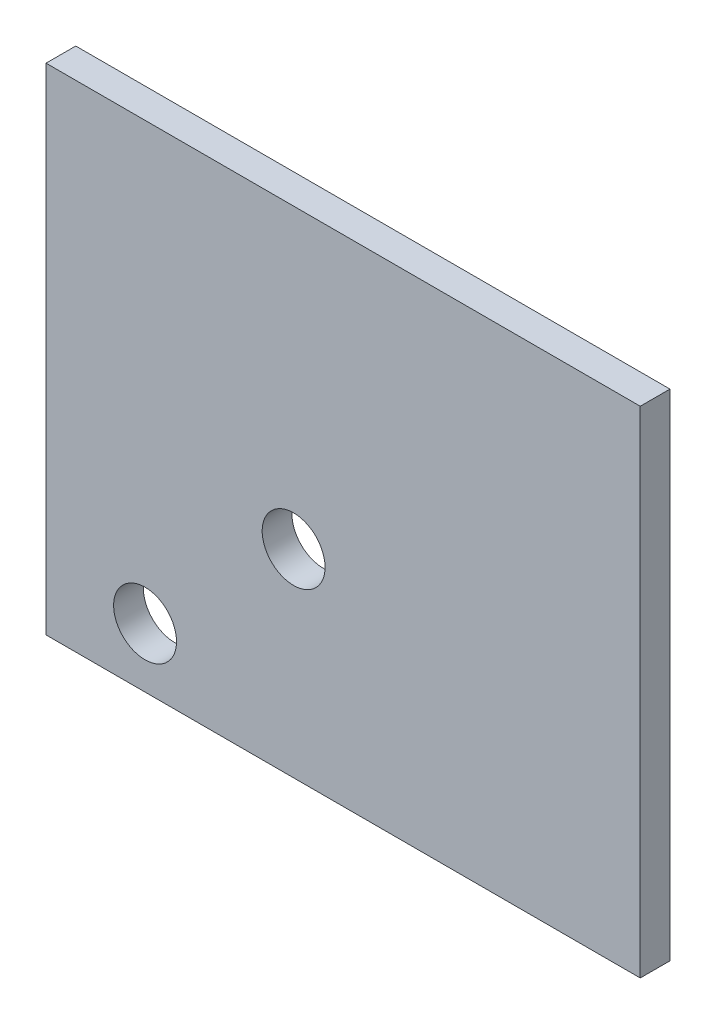
from build123d import *

# Parameters (mm, degrees)
SKETCH1_W           = 60
SKETCH1_H           = 50
BOSS_EXTRUDE1_DEPTH = 3
SKETCH2_R           = 3.175
CUT_EXTRUDE1_DEPTH  = 4


with BuildPart() as part:
    # Sketch1 → Boss-Extrude1 (new body)
    with BuildSketch(Plane.XY):
        with Locations((30, -25)):
            Rectangle(SKETCH1_W, SKETCH1_H)
    extrude(amount=BOSS_EXTRUDE1_DEPTH)

    # Sketch2 → Cut-Extrude1 (cut, through all)
    with BuildSketch(Plane.XY.offset(3)):
        with Locations((25, -30)):
            Circle(SKETCH2_R)
        with Locations((10, -44)):
            Circle(SKETCH2_R)
    extrude(amount=-CUT_EXTRUDE1_DEPTH, mode=Mode.SUBTRACT)


solid = part.part
